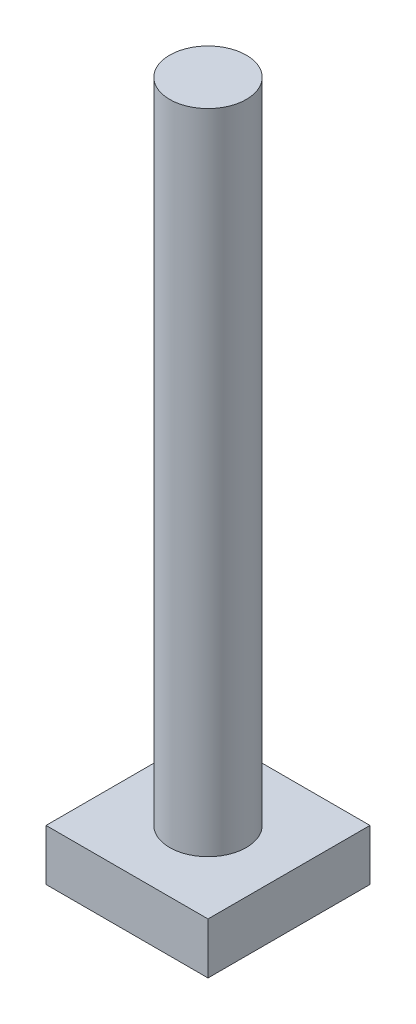
from build123d import *

# Parameters (mm, degrees)
SKETCH1_W           = 19
SKETCH1_H           = 19
BOSS_EXTRUDE1_DEPTH = 6
SKETCH2_R           = 4.5
BOSS_EXTRUDE2_DEPTH = 76


with BuildPart() as part:
    # Sketch1 → Boss-Extrude1 (new body)
    with BuildSketch(Plane(origin=(0, 0, 0), x_dir=(1, 0, 0), z_dir=(0, 1, 0))):
        Rectangle(SKETCH1_W, SKETCH1_H)
    extrude(amount=BOSS_EXTRUDE1_DEPTH)

    # Sketch2 → Boss-Extrude2 (add)
    with BuildSketch(Plane(origin=(0, 6, 0), x_dir=(1, 0, 0), z_dir=(0, 1, 0))):
        with Locations(Location((0, 0, 0), (0, 0, 90))):  # turned: the seam where the file's is
            Circle(SKETCH2_R)
    extrude(amount=BOSS_EXTRUDE2_DEPTH)


solid = part.part
